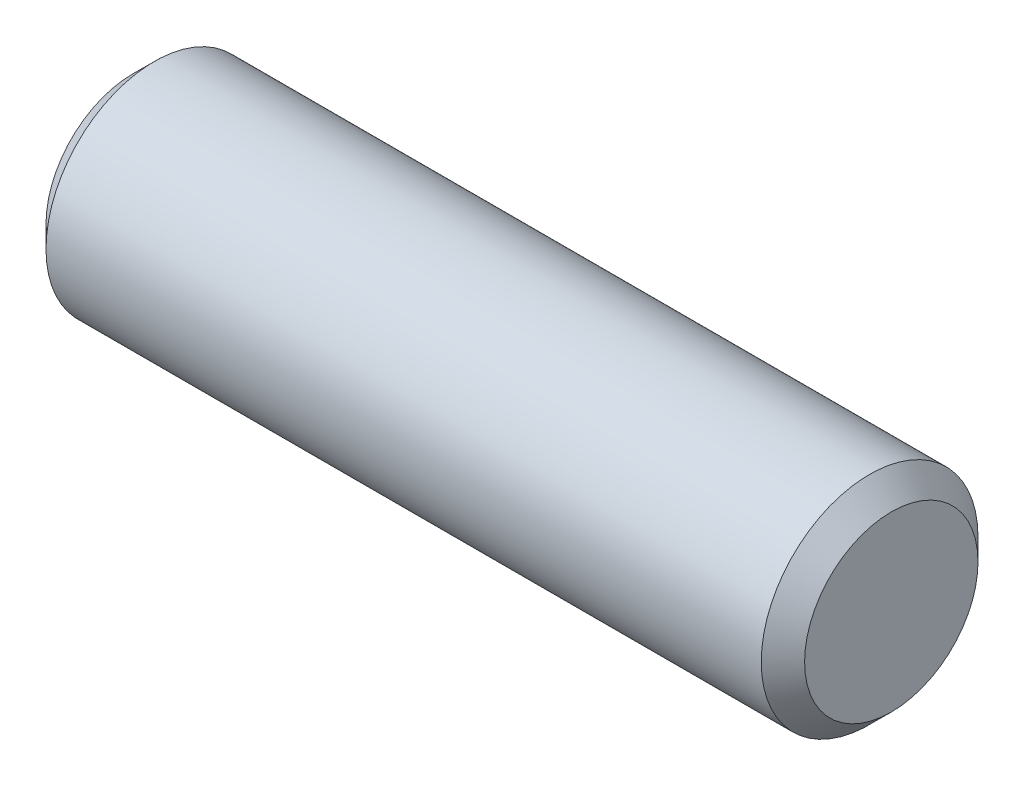
from build123d import *

# Parameters (mm, degrees)
SKETCH2_R           = 3.175
EXTRUDE1_DEPTH      = 11.1125
EXTRUDE1_DEPTH_BACK = 11.1125
CHAMFER1_SIZE       = 0.635


with BuildPart() as part:
    # Sketch2 → Extrude1 (new body, two sides)
    with BuildSketch(Plane(origin=(0, 0, 0), x_dir=(0, 0, -1), z_dir=(1, 0, 0))) as extrude1_sk:
        Circle(SKETCH2_R)
    extrude(amount=EXTRUDE1_DEPTH)
    extrude(extrude1_sk.sketch, amount=-EXTRUDE1_DEPTH_BACK)

    # Chamfer1
    chamfer1_edges = [part.edges().sort_by_distance(p)[0] for p in [
        (-11.1125, 0, 3.175),
        (11.1125, 0, 3.175),
    ]]
    chamfer(chamfer1_edges, length=CHAMFER1_SIZE)


solid = part.part
